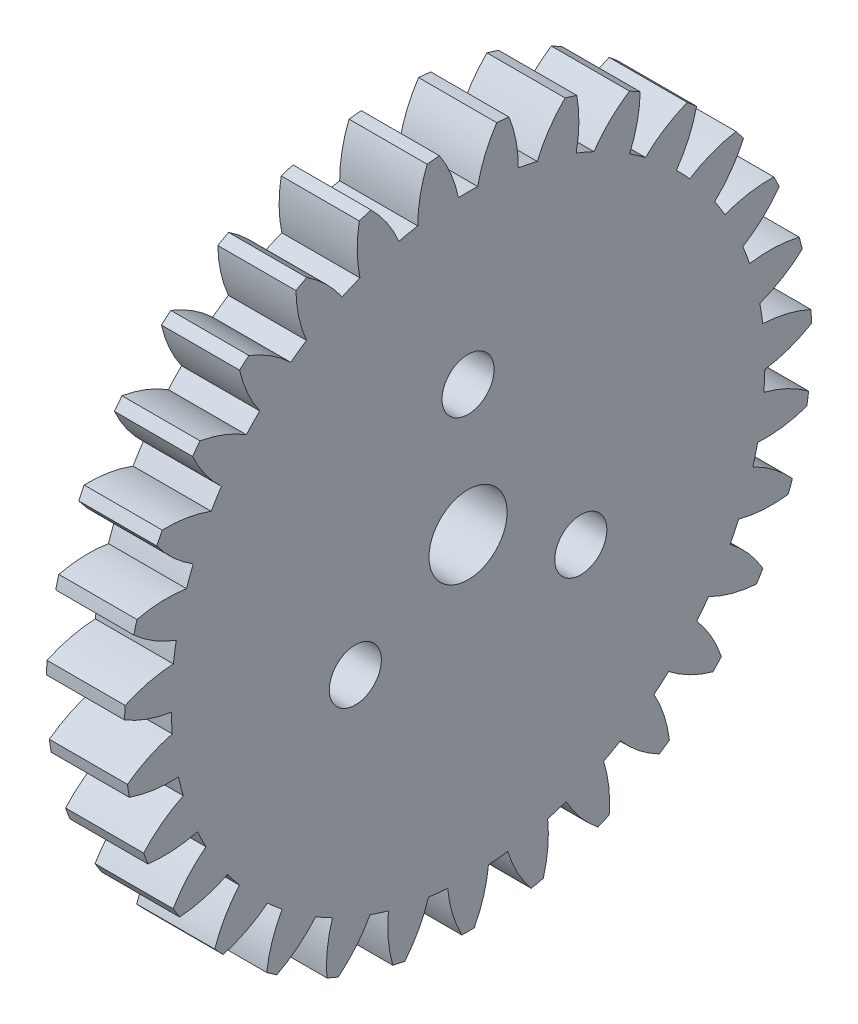
from build123d import *

# Parameters (mm, degrees)
BASPROSKE_W              = 3
BASPROSKE_H              = 13.2
TOOTHCUT_DEPTH           = 19.907141508
TEETHCUTS_COUNT          = 31
TEETHCUTS_ANGLE          = 348.387096774
BORSKE_R                 = 1.5
BORE_DEPTH               = 50.0000508
SKETCH_2_R               = 1
CUT_EXTRUDE_1_DEPTH      = 12
CUT_EXTRUDE_1_DEPTH_BACK = 5


with BuildPart() as part:
    # BasProSke → Base-Revolve (revolve)
    with BuildSketch(Plane(origin=(0, 0, 0), x_dir=(1, 0, 0), z_dir=(0, 1, 0)), mode=Mode.PRIVATE) as base_revolve_sk:
        with Locations((1.5, 6.6)):
            Rectangle(BASPROSKE_W, BASPROSKE_H)
    revolve(base_revolve_sk.sketch.rotate(Axis((-10, 0, 0), (1, 0, 0)), 180), axis=Axis((-10, 0, 0), (1, 0, 0)))

    # TooCutSke → ToothCut (cut, through all)
    with BuildSketch(Plane(origin=(0, 0, 0), x_dir=(0, 0, -1), z_dir=(1, 0, 0))):
        with BuildLine():
            ThreePointArc((0.370639069, 11.392972732), (0, 11.399), (-0.370639069, 11.392972732))
            ThreePointArc((-0.370639069, 11.392972732), (-0.655448149, 12.322294279), (-1.116026507, 13.178227878))
            ThreePointArc((-1.116026507, 13.178227878), (0, 13.2254), (1.116026507, 13.178227878))
            ThreePointArc((1.116026507, 13.178227878), (0.655448149, 12.322294279), (0.370639069, 11.392972732))
        make_face()
    toothcut = extrude(amount=TOOTHCUT_DEPTH, mode=Mode.SUBTRACT)

    # TeethCuts: ToothCut ×31 about axis
    teethcuts_axis = Axis((-10, 0, 0), (1, 0, 0))
    for i in range(1, TEETHCUTS_COUNT):
        add(toothcut.rotate(teethcuts_axis, i * TEETHCUTS_ANGLE / (TEETHCUTS_COUNT - 1)), mode=Mode.SUBTRACT)

    # BorSke → Bore (cut, symmetric)
    with BuildSketch(Plane(origin=(0, 0, 0), x_dir=(0, 0, -1), z_dir=(1, 0, 0))):
        with Locations(Location((0, 0, 0), (0, 0, 180))):
            Circle(BORSKE_R)
    extrude(amount=BORE_DEPTH, both=True, mode=Mode.SUBTRACT)

    # 草图2 → 切除-拉伸1 (cut, two sides)
    with BuildSketch(Plane(origin=(3, 0, 0), x_dir=(0, 0, -1), z_dir=(1, 0, 0))) as cut_extrude_1_sk:
        with Locations(Location((0, 5, 0), (0, 0, 180))):
            Circle(SKETCH_2_R)
        with Locations(Location((4.330127019, -2.5, 0), (0, 0, 180))):
            Circle(SKETCH_2_R)
        with Locations(Location((-4.330127019, -2.5, 0), (0, 0, 180))):
            Circle(SKETCH_2_R)
    extrude(amount=CUT_EXTRUDE_1_DEPTH, mode=Mode.SUBTRACT)
    extrude(cut_extrude_1_sk.sketch, amount=-CUT_EXTRUDE_1_DEPTH_BACK, mode=Mode.SUBTRACT)


solid = part.part
